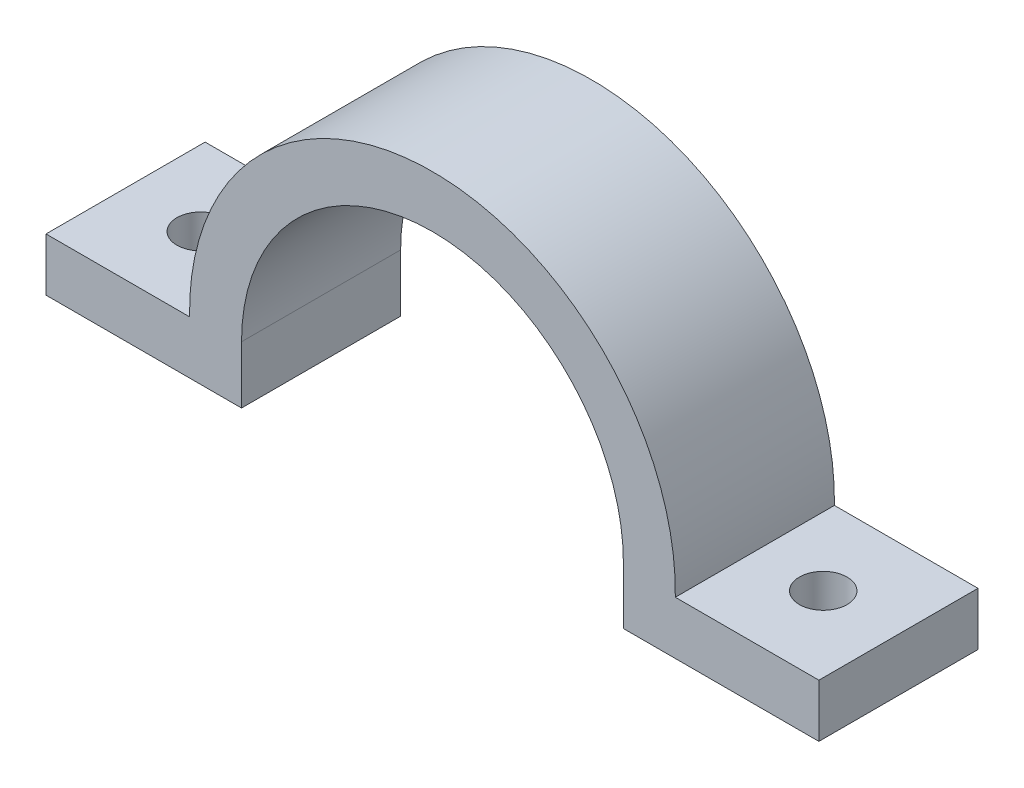
from build123d import *

# Parameters (mm, degrees)
BOSS_EXTRUDE1_DEPTH     = 15
SKETCH5_R               = 2.25
CUT_EXTRUDE1_DEPTH      = 24.3125
CUT_EXTRUDE1_DEPTH_BACK = 6


with BuildPart() as part:
    # Sketch3 → Boss-Extrude1 (new body)
    with BuildSketch(Plane.XY):
        with BuildLine():
            Line((18, 0), (18, -5.4125))
            Line((18, -5.4125), (36.4334, -5.4125))
            Line((36.4334, -5.4125), (36.4334, -0.4125))
            Line((36.4334, -0.4125), (22.896284497, -0.4125))
            ThreePointArc((22.896284497, -0.4125), (0, 22.9), (-22.896284497, -0.4125))
            Line((-22.896284497, -0.4125), (-36.4334, -0.4125))
            Line((-36.4334, -0.4125), (-36.4334, -5.4125))
            Line((-36.4334, -5.4125), (-18, -5.4125))
            Line((-18, -5.4125), (-18, 0))
            ThreePointArc((-18, 0), (0, 18), (18, 0))
        make_face()
    extrude(amount=BOSS_EXTRUDE1_DEPTH)

    # Sketch5 → Cut-Extrude1 (cut, two sides)
    with BuildSketch(Plane(origin=(0, -0.4125, 0), x_dir=(1, 0, 0), z_dir=(0, 1, 0))) as cut_extrude1_sk:
        with Locations((-29.3423, -7.5)):
            Circle(SKETCH5_R)
        with Locations((29.3423, -7.5)):
            Circle(SKETCH5_R)
    extrude(amount=CUT_EXTRUDE1_DEPTH, mode=Mode.SUBTRACT)
    extrude(cut_extrude1_sk.sketch, amount=-CUT_EXTRUDE1_DEPTH_BACK, mode=Mode.SUBTRACT)


solid = part.part
